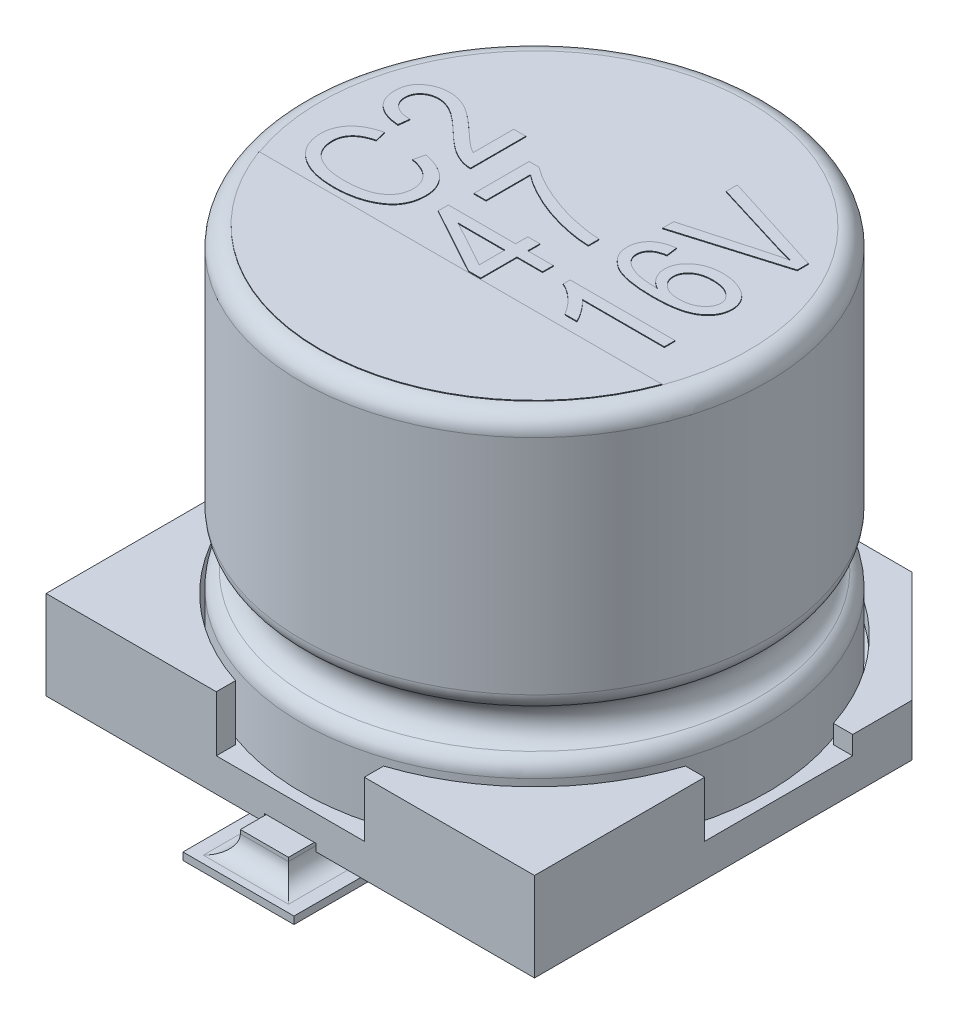
from build123d import *

# Parameters (mm, degrees)
SKETCH1_W                = 6.6
SKETCH1_H                = 6.6
BOSS_EXTRUDE1_DEPTH      = 1.2
CUT_EXTRUDE1_DEPTH       = 0.75
SKETCH3_W                = 3.3
SKETCH3_H                = 0.5
CUT_EXTRUDE2_DEPTH       = 4.3
CUT_EXTRUDE2_DEPTH_BACK  = 4.3
CHAMFER1_SIZE            = 1.5
CUT_EXTRUDE3_DEPTH       = 0.1
BOSS_EXTRUDE4_DEPTH      = 0.3
BOSS_EXTRUDE4_DEPTH_BACK = 0.1
SKETCH8_R                = 0.5
BOSS_EXTRUDE5_DEPTH      = 0.3
SKETCH9_W                = 1.5
SKETCH9_H                = 2
BOSS_EXTRUDE6_DEPTH      = 0.1
FILLET1_R                = 0.25
BOSS_EXTRUDE7_DEPTH      = 0.01


with BuildPart() as part:
    # Sketch1 → Boss-Extrude1 (new body)
    with BuildSketch(Plane(origin=(0, 0.3, 0), x_dir=(1, 0, 0), z_dir=(0, 1, 0))):
        Rectangle(SKETCH1_W, SKETCH1_H)
    extrude(amount=BOSS_EXTRUDE1_DEPTH)

    # Sketch2 → Cut-Extrude1 (cut)
    with BuildSketch(Plane(origin=(0, 1.5, 0), x_dir=(1, 0, 0), z_dir=(0, 1, 0))):
        with BuildLine():
            Line((-3.3, 1), (-3.039736831, 1))
            ThreePointArc((-3.039736831, 1), (-2.2627417, 2.2627417), (-1, 3.039736831))
            Line((-1, 3.039736831), (-1, 3.3))
            Line((-1, 3.3), (1, 3.3))
            Line((1, 3.3), (1, 3.039736831))
            ThreePointArc((1, 3.039736831), (2.2627417, 2.2627417), (3.039736831, 1))
            Line((3.039736831, 1), (3.3, 1))
            Line((3.3, 1), (3.3, -1))
            Line((3.3, -1), (3.039736831, -1))
            ThreePointArc((3.039736831, -1), (2.2627417, -2.2627417), (1, -3.039736831))
            Line((1, -3.039736831), (1, -3.3))
            Line((1, -3.3), (-1, -3.3))
            Line((-1, -3.3), (-1, -3.039736831))
            ThreePointArc((-1, -3.039736831), (-2.2627417, -2.2627417), (-3.039736831, -1))
            Line((-3.039736831, -1), (-3.3, -1))
            Line((-3.3, -1), (-3.3, 1))
        make_face()
    extrude(amount=-CUT_EXTRUDE1_DEPTH, mode=Mode.SUBTRACT)

    # Sketch3 → Cut-Extrude2 (cut, two sides)
    with BuildSketch(Plane(origin=(0, 0, 0), x_dir=(0, 0, -1), z_dir=(1, 0, 0))) as cut_extrude2_sk:
        with Locations((1.65, 1.25)):
            Rectangle(SKETCH3_W, SKETCH3_H)
    extrude(amount=CUT_EXTRUDE2_DEPTH, mode=Mode.SUBTRACT)
    extrude(cut_extrude2_sk.sketch, amount=-CUT_EXTRUDE2_DEPTH_BACK, mode=Mode.SUBTRACT)

    # Chamfer1
    chamfer1_edges = [part.edges().sort_by_distance(p)[0] for p in [
        (3.3, 0.65, -3.3),
        (-3.3, 0.65, -3.3),
    ]]
    chamfer(chamfer1_edges, length=CHAMFER1_SIZE)

    # Sketch7 → Cut-Extrude3 (cut)
    with BuildSketch(Plane.XZ.offset(-0.3)):
        with BuildLine():
            Line((-0.35, 3.3), (0.35, 3.3))
            Line((0.35, 3.3), (0.498675617, 1.261367968))
            ThreePointArc((0.498675617, 1.261367968), (0, 0.725), (-0.498675617, 1.261367968))
            Line((-0.498675617, 1.261367968), (-0.35, 3.3))
        make_face()
        with BuildLine():
            Line((-0.35, -3.3), (0.35, -3.3))
            Line((0.35, -3.3), (0.498675617, -1.261367968))
            ThreePointArc((0.498675617, -1.261367968), (0, -0.725), (-0.498675617, -1.261367968))
            Line((-0.498675617, -1.261367968), (-0.35, -3.3))
        make_face()
    extrude(amount=-CUT_EXTRUDE3_DEPTH, mode=Mode.SUBTRACT)

    # Sketch6 → Boss-Extrude4 (add, two sides)
    with BuildSketch(Plane.XZ.offset(-0.3)) as boss_extrude4_sk:
        with BuildLine():
            Line((-0.325, -1.225), (-0.325, -3.65))
            Line((-0.325, -3.65), (0.325, -3.65))
            Line((0.325, -3.65), (0.325, -1.225))
            ThreePointArc((0.325, -1.225), (0, -0.9), (-0.325, -1.225))
        make_face()
        with BuildLine():
            Line((-0.325, 1.225), (-0.325, 3.65))
            Line((-0.325, 3.65), (0.325, 3.65))
            Line((0.325, 3.65), (0.325, 1.225))
            ThreePointArc((0.325, 1.225), (0, 0.9), (-0.325, 1.225))
        make_face()
    extrude(amount=BOSS_EXTRUDE4_DEPTH)
    extrude(boss_extrude4_sk.sketch, amount=-BOSS_EXTRUDE4_DEPTH_BACK)

    # Sketch8 → Boss-Extrude5 (add)
    with BuildSketch(Plane.XZ.offset(-0.3)):
        with Locations((-2, 2)):
            Circle(SKETCH8_R)
        with Locations((2, 2)):
            Circle(SKETCH8_R)
        with Locations((2, -2)):
            Circle(SKETCH8_R)
        with Locations((-2, -2)):
            Circle(SKETCH8_R)
    extrude(amount=BOSS_EXTRUDE5_DEPTH)

    # Sketch9 → Boss-Extrude6 (add)
    with BuildSketch(Plane(origin=(0, 0, 0), x_dir=(1, 0, 0), z_dir=(0, 1, 0))):
        with Locations((0, 3)):
            Rectangle(SKETCH9_W, SKETCH9_H)
        with Locations((0, -3)):
            Rectangle(SKETCH9_W, SKETCH9_H)
    extrude(amount=BOSS_EXTRUDE6_DEPTH)

    # Fillet1
    fillet1_edges = [part.edges().sort_by_distance(p)[0] for p in [
        (0.325, 0.1, -2.825),
        (0, 0.1, -3.65),
        (-0.325, 0.1, -2.825),
        (-0.325, 0.1, 2.825),
        (0, 0.1, 3.65),
        (0.325, 0.1, 2.825),
    ]]
    fillet(fillet1_edges, radius=FILLET1_R)


with BuildPart() as body_2:
    # Sketch4 → Revolve1 (revolve)
    with BuildSketch(Plane(origin=(0, 0, 0), x_dir=(0, 0, -1), z_dir=(1, 0, 0))):
        with BuildLine():
            Line((0, 0.75), (0, 5.8))
            Line((0, 5.8), (-2.9, 5.8))
            ThreePointArc((-2.9, 5.8), (-3.076776695, 5.726776695), (-3.15, 5.55))
            Line((-3.15, 5.55), (-3.15, 2.539897949))
            ThreePointArc((-3.15, 2.539897949), (-3.113200716, 2.409339707), (-3.013636364, 2.317217063))
            ThreePointArc((-3.013636364, 2.317217063), (-2.85, 2.05), (-3.013636364, 1.782782937))
            ThreePointArc((-3.013636364, 1.782782937), (-3.113200716, 1.690660293), (-3.15, 1.560102051))
            Line((-3.15, 1.560102051), (-3.15, 0.75))
            Line((-3.15, 0.75), (0, 0.75))
        make_face()
    revolve(axis=Axis((0, 0, 0), (0, 1, 0)))

    # Sketch10 → Boss-Extrude7 (add)
    with BuildSketch(Plane(origin=(0, 5.8, 0), x_dir=(1, 0, 0), z_dir=(0, 1, 0))):
        with BuildLine():
            Line((-2.722131518, -1), (2.722131518, -1))
            ThreePointArc((2.722131518, -1), (0, -2.9), (-2.722131518, -1))
        make_face()
        with BuildLine():
            Line((-1.590909091, -0.054545455), (-1.554545455, 0.090909091))
            add(Edge.make_bspline(
                [(-1.554545455, 0.090909091), (-1.535269984, 0.086573907), (-1.497690858, 0.078122106), (-1.443641016, 0.062267336), (-1.39347407, 0.043748021), (-1.347020443, 0.023039775), (-1.304271779, 0.000124477), (-1.26542753, -0.02529249), (-1.230157415, -0.052859494), (-1.199022696, -0.0830881), (-1.1711564, -0.11498153), (-1.147359527, -0.148885394), (-1.126876496, -0.184353775), (-1.110494381, -0.221648338), (-1.097542958, -0.26053486), (-1.088602603, -0.301197149), (-1.082613039, -0.343476895), (-1.082085319, -0.372327427), (-1.081818182, -0.386931818)],
                knots=[0, 0, 0, 0, 5.9261e-05, 0.000115534, 0.000168835, 0.000219573, 0.000268003, 0.000314177, 0.000358679, 0.000402077, 0.00044417, 0.00048555, 0.000526144, 0.000566844, 0.00060754, 0.000648893, 0.000691602, 0.000735385, 0.000735385, 0.000735385, 0.000735385], degree=3))
            add(Edge.make_bspline(
                [(-1.081818182, -0.386931818), (-1.08199604, -0.399821435), (-1.082344685, -0.425088107), (-1.08628588, -0.462271509), (-1.092042775, -0.49811477), (-1.100709737, -0.532535089), (-1.111320422, -0.565607629), (-1.12494552, -0.597015472), (-1.140459369, -0.627260099), (-1.158765073, -0.656028269), (-1.179571172, -0.683485815), (-1.203389889, -0.709483177), (-1.230089597, -0.734193803), (-1.259944493, -0.757429014), (-1.292153583, -0.780002615), (-1.327732387, -0.800693244), (-1.366087752, -0.820236254), (-1.407117451, -0.838589504), (-1.450494312, -0.855557658), (-1.496291355, -0.869438478), (-1.543730677, -0.881811406), (-1.593174601, -0.891633014), (-1.644419194, -0.899736152), (-1.697742163, -0.904867658), (-1.752885478, -0.90849447), (-1.79033462, -0.908889873), (-1.809375, -0.909090909)],
                knots=[0, 0, 0, 0, 3.8653e-05, 7.5769e-05, 0.000112058, 0.000147474, 0.000182152, 0.000216135, 0.000250061, 0.00028403, 0.000318292, 0.000353282, 0.000389669, 0.000427294, 0.000466696, 0.000507575, 0.000550646, 0.000595789, 0.000642375, 0.000690268, 0.000739259, 0.000789402, 0.000841435, 0.000894833, 0.000950052, 0.001007166, 0.001007166, 0.001007166, 0.001007166], degree=3))
            add(Edge.make_bspline(
                [(-1.809375, -0.909090909), (-1.828131477, -0.908891515), (-1.864918777, -0.908500442), (-1.918927074, -0.904879558), (-1.970836199, -0.89976115), (-2.020467971, -0.891629314), (-2.068038414, -0.881875407), (-2.113230745, -0.869546812), (-2.156417451, -0.855465065), (-2.197183074, -0.838717593), (-2.23556886, -0.819854437), (-2.271703348, -0.799665669), (-2.305636674, -0.7782885), (-2.336754909, -0.754647483), (-2.365716723, -0.729906308), (-2.392050099, -0.703226401), (-2.415889386, -0.675051379), (-2.437612676, -0.645533861), (-2.456445194, -0.614609234), (-2.473168151, -0.582906747), (-2.487044041, -0.550190169), (-2.498446352, -0.516578306), (-2.507309721, -0.482103804), (-2.51340371, -0.446753631), (-2.517701953, -0.410616822), (-2.518020918, -0.386187094), (-2.518181818, -0.373863636)],
                knots=[0, 0, 0, 0, 5.6261e-05, 0.000110346, 0.000162332, 0.00021268, 0.000261154, 0.000307947, 0.000353135, 0.000397345, 0.000440035, 0.00048137, 0.000521484, 0.000560234, 0.000598505, 0.000635669, 0.000672553, 0.000709147, 0.000745495, 0.000781075, 0.000816587, 0.000851984, 0.000887469, 0.000923246, 0.000959544, 0.000996494, 0.000996494, 0.000996494, 0.000996494], degree=3))
            add(Edge.make_bspline(
                [(-2.518181818, -0.373863636), (-2.517836245, -0.360403658), (-2.517157421, -0.333963692), (-2.51232314, -0.2949276), (-2.50375071, -0.257491322), (-2.491963894, -0.221400738), (-2.477319506, -0.186648435), (-2.458926486, -0.153497861), (-2.437231843, -0.121829676), (-2.412151492, -0.091753334), (-2.384064112, -0.063268457), (-2.352642727, -0.037053667), (-2.318021615, -0.013198288), (-2.280592352, 0.008720064), (-2.239836161, 0.028077805), (-2.196104803, 0.045195718), (-2.149383072, 0.060899358), (-2.116737437, 0.06871843), (-2.1, 0.072727273)],
                knots=[0, 0, 0, 0, 4.0377e-05, 7.9314e-05, 0.00011777, 0.000155413, 0.000193089, 0.000230727, 0.000268944, 0.000308083, 0.000348059, 0.000388798, 0.000430644, 0.000474058, 0.000518786, 0.000565843, 0.000614895, 0.000666503, 0.000666503, 0.000666503, 0.000666503], degree=3))
            Line((-2.1, 0.072727273), (-2.063636364, -0.072727273))
            add(Edge.make_bspline(
                [(-2.063636364, -0.072727273), (-2.075415657, -0.076014842), (-2.09838882, -0.082426589), (-2.131385283, -0.093836475), (-2.16212884, -0.106315751), (-2.190702493, -0.119878322), (-2.216858294, -0.134981345), (-2.240809391, -0.151183398), (-2.262622459, -0.168512213), (-2.281837552, -0.18733177), (-2.299174934, -0.207015726), (-2.314027101, -0.228167261), (-2.326434713, -0.250610755), (-2.336864821, -0.274143399), (-2.344710122, -0.29883956), (-2.350488764, -0.324780444), (-2.353897302, -0.351897099), (-2.354327694, -0.370445051), (-2.354545455, -0.379829545)],
                knots=[0, 0, 0, 0, 3.6682e-05, 7.1541e-05, 0.000104671, 0.000136183, 0.000166347, 0.000195186, 0.000222871, 0.000249792, 0.000275769, 0.000301463, 0.000327153, 0.000352594, 0.000378559, 0.000404751, 0.000432236, 0.000460383, 0.000460383, 0.000460383, 0.000460383], degree=3))
            add(Edge.make_bspline(
                [(-2.354545455, -0.379829545), (-2.35385919, -0.398352683), (-2.352520049, -0.434497777), (-2.341380909, -0.486774554), (-2.32356338, -0.535415072), (-2.302183567, -0.572435813), (-2.281676826, -0.599884003), (-2.264145966, -0.619341158), (-2.244571744, -0.637656309), (-2.223156065, -0.655079621), (-2.199729148, -0.671452407), (-2.174116674, -0.68659933), (-2.146678058, -0.700674648), (-2.117280199, -0.71391907), (-2.085725363, -0.725452856), (-2.052144458, -0.735658997), (-2.016608107, -0.744497484), (-1.97904312, -0.751570884), (-1.939483915, -0.756840566), (-1.897893335, -0.760900414), (-1.854284805, -0.763081061), (-1.824528656, -0.763448991), (-1.809375, -0.763636364)],
                knots=[0, 0, 0, 0, 5.5521e-05, 0.00010834, 0.000159579, 0.000210356, 0.000235924, 0.000262277, 0.000288806, 0.00031627, 0.000345037, 0.000374464, 0.000405467, 0.000437514, 0.00047113, 0.000506178, 0.000542765, 0.000580932, 0.000620788, 0.000662455, 0.000706264, 0.000751727, 0.000751727, 0.000751727, 0.000751727], degree=3))
            add(Edge.make_bspline(
                [(-1.809375, -0.763636364), (-1.7866406, -0.763277052), (-1.742545554, -0.76258014), (-1.678505163, -0.758136361), (-1.618781, -0.750361716), (-1.56357216, -0.73894853), (-1.512700987, -0.724850823), (-1.466148021, -0.70769878), (-1.424108709, -0.686842239), (-1.3864956, -0.663014636), (-1.353335841, -0.636428646), (-1.324444791, -0.607743969), (-1.300117612, -0.576779572), (-1.279890257, -0.543911532), (-1.264590564, -0.508650459), (-1.253399106, -0.471491449), (-1.246760222, -0.43214949), (-1.24589616, -0.405233711), (-1.245454545, -0.391477273)],
                knots=[0, 0, 0, 0, 6.8203e-05, 0.000132285, 0.000192472, 0.000248745, 0.00030127, 0.000350714, 0.000397341, 0.00044179, 0.000484028, 0.000524606, 0.000563651, 0.000601898, 0.00064006, 0.000678618, 0.000718083, 0.000759339, 0.000759339, 0.000759339, 0.000759339], degree=3))
            add(Edge.make_bspline(
                [(-1.245454545, -0.391477273), (-1.245736078, -0.381236028), (-1.246290868, -0.361054538), (-1.250438864, -0.331302808), (-1.25684292, -0.302519826), (-1.266278016, -0.274802746), (-1.278603487, -0.248317216), (-1.293435518, -0.222915999), (-1.310955246, -0.1985858), (-1.331001303, -0.175372212), (-1.35388971, -0.153621502), (-1.379633959, -0.133728141), (-1.407978223, -0.115505231), (-1.439304302, -0.099629671), (-1.473213821, -0.085434106), (-1.509927287, -0.072944059), (-1.549417404, -0.062419489), (-1.576856124, -0.057212339), (-1.590909091, -0.054545455)],
                knots=[0, 0, 0, 0, 3.0715e-05, 6.0527e-05, 8.9954e-05, 0.000119062, 0.00014817, 0.000177454, 0.000207176, 0.00023799, 0.000269338, 0.00030173, 0.000335459, 0.000370273, 0.000406942, 0.000445663, 0.000486527, 0.000529427, 0.000529427, 0.000529427, 0.000529427], degree=3))
        make_face()
        with BuildLine():
            Line((-1.263636364, 0.981818182), (-1.1, 0.981818182))
            Line((-1.1, 0.981818182), (-1.1, 0.236363636))
            add(Edge.make_bspline(
                [(-1.1, 0.236363636), (-1.108526139, 0.236329121), (-1.125800237, 0.236259193), (-1.152136122, 0.238584079), (-1.179109616, 0.243360755), (-1.207080544, 0.249460089), (-1.235681047, 0.258108257), (-1.265050018, 0.268695301), (-1.295114638, 0.281186756), (-1.326051768, 0.295814413), (-1.358163014, 0.312902254), (-1.391293946, 0.333544589), (-1.426060056, 0.357133193), (-1.462027805, 0.384239565), (-1.499539059, 0.414376038), (-1.538420082, 0.447691337), (-1.578884511, 0.484046326), (-1.605760934, 0.509953354), (-1.619602273, 0.523295455)],
                knots=[0, 0, 0, 0, 2.557e-05, 5.1805e-05, 7.9173e-05, 0.000107707, 0.000137639, 0.000168732, 0.000201336, 0.000235267, 0.000271364, 0.000310392, 0.000352311, 0.000397368, 0.000445463, 0.000496645, 0.000550956, 0.000608626, 0.000608626, 0.000608626, 0.000608626], degree=3))
            add(Edge.make_bspline(
                [(-1.619602273, 0.523295455), (-1.635637271, 0.538798259), (-1.666511412, 0.568647703), (-1.712098974, 0.610657945), (-1.754472047, 0.648828469), (-1.79439686, 0.682396652), (-1.831329649, 0.711958454), (-1.865217609, 0.737811297), (-1.896829804, 0.758719674), (-1.934026094, 0.781294777), (-1.978307687, 0.802816931), (-2.029924889, 0.821843734), (-2.079823364, 0.834137484), (-2.112720366, 0.835636031), (-2.128693182, 0.836363636)],
                knots=[0, 0, 0, 0, 6.6909e-05, 0.000128827, 0.000185969, 0.000237984, 0.00028528, 0.000327894, 0.000365793, 0.000398924, 0.000458385, 0.000513117, 0.000563838, 0.000611708, 0.000611708, 0.000611708, 0.000611708], degree=3))
            add(Edge.make_bspline(
                [(-2.128693182, 0.836363636), (-2.137511466, 0.836262209), (-2.154734496, 0.836064109), (-2.179886592, 0.832696429), (-2.20381126, 0.827895556), (-2.226676172, 0.821550373), (-2.248124534, 0.812577909), (-2.268306101, 0.801705089), (-2.28748668, 0.78927231), (-2.305000247, 0.774764414), (-2.320799928, 0.758906262), (-2.334944309, 0.74215364), (-2.34650537, 0.724224166), (-2.356081715, 0.705487317), (-2.363408979, 0.685830846), (-2.368899131, 0.665304412), (-2.372018106, 0.643845165), (-2.37248854, 0.629270992), (-2.372727273, 0.621875)],
                knots=[0, 0, 0, 0, 2.6434e-05, 5.1629e-05, 7.5976e-05, 9.9624e-05, 0.000122679, 0.000145557, 0.000168329, 0.000191136, 0.000213634, 0.000235423, 0.000256777, 0.000277486, 0.000298434, 0.000319589, 0.000341123, 0.000363312, 0.000363312, 0.000363312, 0.000363312], degree=3))
            add(Edge.make_bspline(
                [(-2.372727273, 0.621875), (-2.37256065, 0.613900574), (-2.372235395, 0.59833413), (-2.36816798, 0.575651584), (-2.362773189, 0.553892243), (-2.354244328, 0.533328095), (-2.34393617, 0.513567435), (-2.330480705, 0.495423159), (-2.315464229, 0.477851762), (-2.297847597, 0.461699801), (-2.277843958, 0.447282103), (-2.255995759, 0.434340392), (-2.231759102, 0.423909264), (-2.205732976, 0.415143025), (-2.177605795, 0.408257148), (-2.147464409, 0.403659769), (-2.115321715, 0.400286651), (-2.093191418, 0.400097308), (-2.081818182, 0.4)],
                knots=[0, 0, 0, 0, 2.3891e-05, 4.6636e-05, 6.8962e-05, 9.1013e-05, 0.000113256, 0.000135647, 0.000158604, 0.00018253, 0.000207134, 0.000232471, 0.000258547, 0.000286127, 0.000314791, 0.00034529, 0.000377544, 0.000411645, 0.000411645, 0.000411645, 0.000411645], degree=3))
            Line((-2.081818182, 0.4), (-2.1, 0.254545455))
            add(Edge.make_bspline(
                [(-2.1, 0.254545455), (-2.116878864, 0.256044403), (-2.149624625, 0.258952431), (-2.197028868, 0.266582878), (-2.241012726, 0.277169397), (-2.282009501, 0.289743194), (-2.319529308, 0.305538117), (-2.354259092, 0.323315632), (-2.385594771, 0.344104712), (-2.41358887, 0.367471303), (-2.438135931, 0.393219601), (-2.459470498, 0.420881428), (-2.477973713, 0.450326621), (-2.492661358, 0.48196961), (-2.504113656, 0.515601078), (-2.512301557, 0.551095677), (-2.517184689, 0.588595521), (-2.517844532, 0.61418989), (-2.518181818, 0.627272727)],
                knots=[0, 0, 0, 0, 5.0826e-05, 9.8605e-05, 0.000143876, 0.000186465, 0.00022709, 0.000265845, 0.000303351, 0.000339652, 0.000375017, 0.00040985, 0.0004443, 0.000479123, 0.00051425, 0.000550705, 0.000588233, 0.000627474, 0.000627474, 0.000627474, 0.000627474], degree=3))
            add(Edge.make_bspline(
                [(-2.518181818, 0.627272727), (-2.51777024, 0.641399278), (-2.51696883, 0.66890602), (-2.511606791, 0.708928303), (-2.502364468, 0.746367717), (-2.488775473, 0.780952896), (-2.472086687, 0.813059839), (-2.451359855, 0.842398159), (-2.426718946, 0.8689373), (-2.398630231, 0.892533787), (-2.368318477, 0.913392859), (-2.336619301, 0.931592245), (-2.304062219, 0.947379151), (-2.270283829, 0.959716965), (-2.235737761, 0.970020381), (-2.199900262, 0.976493207), (-2.163184854, 0.98105003), (-2.138366747, 0.981560685), (-2.125852273, 0.981818182)],
                knots=[0, 0, 0, 0, 4.2376e-05, 8.2514e-05, 0.000120892, 0.000157769, 0.000193732, 0.000229202, 0.000265187, 0.000302072, 0.000339031, 0.000375431, 0.000411646, 0.000447423, 0.000483207, 0.000519646, 0.000556541, 0.000594068, 0.000594068, 0.000594068, 0.000594068], degree=3))
            add(Edge.make_bspline(
                [(-2.125852273, 0.981818182), (-2.11457728, 0.981575571), (-2.092174188, 0.98109351), (-2.058747505, 0.977957666), (-2.025770218, 0.972422318), (-1.992925237, 0.965234918), (-1.960721139, 0.955035926), (-1.928646367, 0.943490202), (-1.897063055, 0.92948583), (-1.865353596, 0.912954493), (-1.832400362, 0.893593658), (-1.797582813, 0.870413663), (-1.75999161, 0.843695117), (-1.720068327, 0.812894269), (-1.677371403, 0.778503223), (-1.632239704, 0.74007834), (-1.584581066, 0.697748991), (-1.552225242, 0.667949952), (-1.535511364, 0.652556818)],
                knots=[0, 0, 0, 0, 3.3826e-05, 6.7211e-05, 0.000100605, 0.0001341, 0.000167978, 0.000201861, 0.000236331, 0.000271528, 0.000309093, 0.000350933, 0.00039697, 0.000447427, 0.000502177, 0.000561433, 0.000625227, 0.000693392, 0.000693392, 0.000693392, 0.000693392], degree=3))
            add(Edge.make_bspline(
                [(-1.535511364, 0.652556818), (-1.525120683, 0.642774978), (-1.505263257, 0.624081097), (-1.476459517, 0.597787932), (-1.450627532, 0.573694445), (-1.427113376, 0.552619595), (-1.406420699, 0.533879053), (-1.387872289, 0.518474586), (-1.372371784, 0.50522937), (-1.347533386, 0.485906517), (-1.312497714, 0.461520393), (-1.279547873, 0.444555837), (-1.263636364, 0.436363636)],
                knots=[0, 0, 0, 0, 4.2811e-05, 8.1815e-05, 0.000116998, 0.000148778, 0.000176546, 0.000200736, 0.000221105, 0.0002377, 0.000295143, 0.000348787, 0.000348787, 0.000348787, 0.000348787], degree=3))
            Line((-1.263636364, 0.436363636), (-1.263636364, 0.981818182))
        make_face()
        Polygon((0.6, -0.490909091), (0.254545455, -0.490909091), (0.254545455, -0.981818182), (0.090909091, -0.981818182), (-0.818181818, -0.482670455), (-0.818181818, -0.345454545), (0.090909091, -0.345454545), (0.090909091, -0.181818182), (0.254545455, -0.181818182), (0.254545455, -0.345454545), (0.6, -0.345454545), align=None)
        Polygon((0.090909091, -0.490909091), (-0.541761364, -0.490909091), (0.090909091, -0.838352273), align=None, mode=Mode.SUBTRACT)
        with BuildLine():
            Line((-0.618181818, -0.036363636), (-0.781818182, -0.036363636))
            Line((-0.781818182, -0.036363636), (-0.781818182, 0.709090909))
            Line((-0.781818182, 0.709090909), (-0.648011364, 0.709090909))
            add(Edge.make_bspline(
                [(-0.648011364, 0.709090909), (-0.629493997, 0.695259816), (-0.591802758, 0.667107268), (-0.531511589, 0.627736674), (-0.467300458, 0.589447284), (-0.399115474, 0.552202178), (-0.326735965, 0.516442976), (-0.250395077, 0.481792677), (-0.169863353, 0.448671938), (-0.086180255, 0.416771358), (-0.000509186, 0.387072726), (0.085833546, 0.360699392), (0.172037252, 0.337560436), (0.258041112, 0.318119267), (0.343740707, 0.301430866), (0.429233175, 0.288433289), (0.514618592, 0.278624638), (0.571572289, 0.274690798), (0.6, 0.272727273)],
                knots=[0, 0, 0, 0, 6.9323e-05, 0.000141105, 0.000215892, 0.000293569, 0.000374119, 0.000458032, 0.000545029, 0.000635305, 0.000726675, 0.000816989, 0.000906092, 0.000994375, 0.001081459, 0.001167964, 0.001253736, 0.001339214, 0.001339214, 0.001339214, 0.001339214], degree=3))
            Line((0.6, 0.272727273), (0.6, 0.127272727))
            add(Edge.make_bspline(
                [(0.6, 0.127272727), (0.585031616, 0.127721783), (0.554496113, 0.128637858), (0.507812363, 0.132321595), (0.459263961, 0.136926159), (0.408898623, 0.14395977), (0.356690679, 0.152404131), (0.302660797, 0.16282712), (0.246691588, 0.174269157), (0.169998372, 0.192613669), (0.07400088, 0.218383212), (-0.039052852, 0.255716866), (-0.149665888, 0.297377526), (-0.256248385, 0.345139752), (-0.357722591, 0.395822213), (-0.451901767, 0.449612447), (-0.539097534, 0.503996466), (-0.592310728, 0.544126176), (-0.618181818, 0.563636364)],
                knots=[0, 0, 0, 0, 4.4919e-05, 9.1634e-05, 0.000140453, 0.000191197, 0.00024416, 0.000299098, 0.000356263, 0.000415524, 0.000535646, 0.000654323, 0.000772562, 0.000890077, 0.001004549, 0.001112692, 0.001215383, 0.001312548, 0.001312548, 0.001312548, 0.001312548], degree=3))
            Line((-0.618181818, 0.563636364), (-0.618181818, -0.036363636))
        make_face()
        with BuildLine():
            Line((2.3, -0.4), (2.3, -0.545454545))
            Line((2.3, -0.545454545), (1.190909091, -0.545454545))
            add(Edge.make_bspline(
                [(1.190909091, -0.545454545), (1.201187583, -0.554390899), (1.222489747, -0.572911482), (1.252821972, -0.60494637), (1.283744861, -0.640961759), (1.314142583, -0.680475653), (1.343094492, -0.721004913), (1.369022417, -0.760723301), (1.391194556, -0.798732178), (1.403286622, -0.824158704), (1.409090909, -0.836363636)],
                knots=[0, 0, 0, 0, 4.0839e-05, 8.4639e-05, 0.000132185, 0.000183214, 0.000234138, 0.000281575, 0.00032548, 0.00036601, 0.00036601, 0.00036601, 0.00036601], degree=3))
            Line((1.409090909, -0.836363636), (1.245454545, -0.836363636))
            add(Edge.make_bspline(
                [(1.245454545, -0.836363636), (1.233642199, -0.816748251), (1.210118652, -0.777685441), (1.169417041, -0.722834292), (1.125143852, -0.671296873), (1.077511838, -0.624163795), (1.028626141, -0.581775948), (0.979606546, -0.545645228), (0.931206448, -0.51592592), (0.897903798, -0.50135576), (0.881818182, -0.494318182)],
                knots=[0, 0, 0, 0, 6.8659e-05, 0.00013673, 0.000204613, 0.000272311, 0.000337575, 0.000398545, 0.000454866, 0.000507487, 0.000507487, 0.000507487, 0.000507487], degree=3))
            Line((0.881818182, -0.494318182), (0.881818182, -0.4))
            Line((0.881818182, -0.4), (2.3, -0.4))
        make_face()
        with BuildLine():
            Line((1.227272727, 0.690909091), (1.245454545, 0.545454545))
            add(Edge.make_bspline(
                [(1.245454545, 0.545454545), (1.228888789, 0.542092373), (1.197868713, 0.535796564), (1.155846338, 0.522141027), (1.120711583, 0.506926235), (1.102068626, 0.492856198), (1.093465909, 0.486363636)],
                knots=[0, 0, 0, 0, 5.0658e-05, 9.486e-05, 0.00013248, 0.000164714, 0.000164714, 0.000164714, 0.000164714], degree=3))
            add(Edge.make_bspline(
                [(1.093465909, 0.486363636), (1.088151366, 0.481642121), (1.077817659, 0.47246151), (1.06443174, 0.457203296), (1.052895267, 0.441493714), (1.043396289, 0.424973026), (1.036294313, 0.407446484), (1.031211008, 0.389240358), (1.027970319, 0.370378725), (1.02750664, 0.357588599), (1.027272727, 0.351136364)],
                knots=[0, 0, 0, 0, 2.1309e-05, 4.1433e-05, 6.0753e-05, 7.9711e-05, 9.8439e-05, 0.000117327, 0.000136335, 0.000155687, 0.000155687, 0.000155687, 0.000155687], degree=3))
            add(Edge.make_bspline(
                [(1.027272727, 0.351136364), (1.027643592, 0.341140794), (1.028378351, 0.32133756), (1.036299776, 0.29259891), (1.048194188, 0.265239754), (1.065396873, 0.239642765), (1.087299439, 0.215759119), (1.113695286, 0.193080537), (1.145190329, 0.172459963), (1.1683489, 0.160489366), (1.180397727, 0.154261364)],
                knots=[0, 0, 0, 0, 2.9916e-05, 5.927e-05, 8.8778e-05, 0.000119113, 0.000151295, 0.000185745, 0.00022325, 0.000263926, 0.000263926, 0.000263926, 0.000263926], degree=3))
            add(Edge.make_bspline(
                [(1.180397727, 0.154261364), (1.191962823, 0.149034298), (1.216006909, 0.138167115), (1.255189325, 0.125423701), (1.298133663, 0.114225257), (1.345214897, 0.105828484), (1.395945211, 0.098194453), (1.450776138, 0.093327091), (1.50943165, 0.090145929), (1.549900669, 0.089712047), (1.570738636, 0.089488636)],
                knots=[0, 0, 0, 0, 3.8049e-05, 7.9105e-05, 0.00012341, 0.000171105, 0.000222491, 0.000277276, 0.000336166, 0.000398676, 0.000398676, 0.000398676, 0.000398676], degree=3))
            add(Edge.make_bspline(
                [(1.570738636, 0.089488636), (1.556560753, 0.097725733), (1.52897336, 0.113753515), (1.492799332, 0.143597703), (1.461338332, 0.17571945), (1.435700878, 0.211098792), (1.41578701, 0.248661976), (1.401491233, 0.287551141), (1.392514241, 0.327527921), (1.391445574, 0.354594227), (1.390909091, 0.368181818)],
                knots=[0, 0, 0, 0, 4.9116e-05, 9.557e-05, 0.000140173, 0.000183701, 0.000226147, 0.000267312, 0.00030771, 0.000348434, 0.000348434, 0.000348434, 0.000348434], degree=3))
            add(Edge.make_bspline(
                [(1.390909091, 0.368181818), (1.391301908, 0.37947435), (1.392076125, 0.401731205), (1.397935225, 0.434574693), (1.407678703, 0.46619161), (1.421078749, 0.496875415), (1.438700941, 0.526321122), (1.459989424, 0.55473775), (1.485384314, 0.581768718), (1.513778366, 0.607887329), (1.545762775, 0.631597453), (1.580606808, 0.652393143), (1.617945468, 0.67013848), (1.658109338, 0.68422275), (1.700620967, 0.695643016), (1.74586758, 0.703570359), (1.793660139, 0.708012019), (1.826411295, 0.708725543), (1.843181818, 0.709090909)],
                knots=[0, 0, 0, 0, 3.3865e-05, 6.6746e-05, 9.9726e-05, 0.000132927, 0.000166935, 0.000202447, 0.000239235, 0.000278048, 0.000318048, 0.000358438, 0.000399612, 0.000441845, 0.000485947, 0.000531533, 0.000579476, 0.000629789, 0.000629789, 0.000629789, 0.000629789], degree=3))
            add(Edge.make_bspline(
                [(1.843181818, 0.709090909), (1.865940629, 0.708510813), (1.910522693, 0.707374467), (1.975798442, 0.697853255), (2.037715145, 0.681816353), (2.086798735, 0.663659874), (2.123564453, 0.646174993), (2.149231877, 0.632320376), (2.172901252, 0.617317941), (2.195178857, 0.602033393), (2.214942951, 0.584975548), (2.233426741, 0.567774568), (2.249571641, 0.549145547), (2.268698238, 0.523655154), (2.28874725, 0.490162677), (2.30557452, 0.447135236), (2.316278443, 0.402226709), (2.317544283, 0.371460964), (2.318181818, 0.355965909)],
                knots=[0, 0, 0, 0, 6.8253e-05, 0.000133701, 0.000197368, 0.000259846, 0.000290344, 0.000319456, 0.000347281, 0.000374395, 0.000400403, 0.000425521, 0.000450081, 0.000474229, 0.000521099, 0.000566627, 0.000612387, 0.000658819, 0.000658819, 0.000658819, 0.000658819], degree=3))
            add(Edge.make_bspline(
                [(2.318181818, 0.355965909), (2.317691664, 0.342010757), (2.316727601, 0.314562996), (2.309050836, 0.274378579), (2.296867201, 0.236064049), (2.27958791, 0.199563657), (2.257265816, 0.164973364), (2.229710866, 0.132591642), (2.197512918, 0.10196948), (2.160507284, 0.073047837), (2.117363709, 0.047045263), (2.067941211, 0.024355548), (2.011839884, 0.005399942), (1.94919517, -0.009536), (1.880148929, -0.021787042), (1.804634104, -0.030399859), (1.722513582, -0.035469899), (1.665632603, -0.036058055), (1.636079545, -0.036363636)],
                knots=[0, 0, 0, 0, 4.184e-05, 8.2292e-05, 0.000122273, 0.000162176, 0.000203074, 0.000245414, 0.000289419, 0.000336187, 0.000386029, 0.000440178, 0.000499023, 0.000563378, 0.000633205, 0.000709285, 0.000791262, 0.000879915, 0.000879915, 0.000879915, 0.000879915], degree=3))
            add(Edge.make_bspline(
                [(1.636079545, -0.036363636), (1.603305255, -0.036094702), (1.540170663, -0.035576643), (1.449090047, -0.030014357), (1.365309726, -0.021600486), (1.288866255, -0.009061535), (1.219622777, 0.006472035), (1.157689709, 0.026126761), (1.102740274, 0.048688873), (1.055355342, 0.075814664), (1.014476479, 0.105480524), (0.97930089, 0.137249763), (0.949000925, 0.170571279), (0.924311914, 0.206245054), (0.905466497, 0.244219922), (0.891582235, 0.283958428), (0.883542405, 0.325909704), (0.882398812, 0.354511992), (0.881818182, 0.369034091)],
                knots=[0, 0, 0, 0, 9.831e-05, 0.000189379, 0.000273648, 0.000350803, 0.000421647, 0.000486336, 0.000545537, 0.000599485, 0.000649718, 0.000696786, 0.000741447, 0.000784551, 0.000826477, 0.000868254, 0.000910487, 0.000954046, 0.000954046, 0.000954046, 0.000954046], degree=3))
            add(Edge.make_bspline(
                [(0.881818182, 0.369034091), (0.88211765, 0.379555387), (0.88270796, 0.400294916), (0.886582427, 0.430807456), (0.893814712, 0.459878127), (0.903566333, 0.487625163), (0.915663578, 0.514288677), (0.931219954, 0.539251809), (0.949252006, 0.563066082), (0.969992985, 0.585418625), (0.993267363, 0.6063684), (1.019605328, 0.624677841), (1.04811713, 0.641196369), (1.079013501, 0.655861124), (1.11254524, 0.667933113), (1.148573562, 0.677796225), (1.186975614, 0.685905338), (1.21360504, 0.689211954), (1.227272727, 0.690909091)],
                knots=[0, 0, 0, 0, 3.1566e-05, 6.2223e-05, 9.2058e-05, 0.000121258, 0.000150366, 0.000179698, 0.000209301, 0.000239859, 0.000271048, 0.000303049, 0.000335891, 0.000369822, 0.000405501, 0.000442652, 0.00048182, 0.000523122, 0.000523122, 0.000523122, 0.000523122], degree=3))
        make_face()
        with BuildLine():
            add(Edge.make_bspline(
                [(1.837784091, 0.109090909), (1.850102241, 0.109299566), (1.874125052, 0.109706487), (1.90926333, 0.113153393), (1.942538217, 0.118929419), (1.974140993, 0.126260744), (2.003549298, 0.136806756), (2.031395969, 0.148861304), (2.057161391, 0.163737555), (2.08105205, 0.180441229), (2.102391824, 0.198691241), (2.121071193, 0.217945946), (2.137105456, 0.237680349), (2.149972193, 0.258474392), (2.160460141, 0.2797765), (2.167444219, 0.302118458), (2.171929301, 0.325009273), (2.172460461, 0.340509441), (2.172727273, 0.348295455)],
                knots=[0, 0, 0, 0, 3.6949e-05, 7.2058e-05, 0.000105779, 0.000138233, 0.00016923, 0.000199373, 0.000229148, 0.00025831, 0.000286721, 0.00031324, 0.000338707, 0.000362828, 0.000386463, 0.000409732, 0.000432855, 0.000456194, 0.000456194, 0.000456194, 0.000456194], degree=3))
            add(Edge.make_bspline(
                [(2.172727273, 0.348295455), (2.172428819, 0.355224503), (2.17183519, 0.369006472), (2.167840785, 0.389330113), (2.16075589, 0.408891414), (2.151411533, 0.428068793), (2.139004698, 0.446609612), (2.123928734, 0.464502475), (2.105983244, 0.481521888), (2.086082333, 0.498395968), (2.063343969, 0.513403563), (2.038940857, 0.527460465), (2.011901072, 0.538178344), (1.98325262, 0.547808023), (1.9522647, 0.554632144), (1.919498862, 0.560257618), (1.884510312, 0.562846113), (1.860608561, 0.563367677), (1.848295455, 0.563636364)],
                knots=[0, 0, 0, 0, 2.0787e-05, 4.1346e-05, 6.1832e-05, 8.305e-05, 0.000105191, 0.000128579, 0.00015309, 0.000179316, 0.000206736, 0.000234716, 0.000263628, 0.000293814, 0.000325307, 0.000358701, 0.000393476, 0.000430425, 0.000430425, 0.000430425, 0.000430425], degree=3))
            add(Edge.make_bspline(
                [(1.848295455, 0.563636364), (1.836264519, 0.563378694), (1.812926375, 0.562878854), (1.778827026, 0.560144934), (1.746928488, 0.555059652), (1.716950204, 0.548000868), (1.689270215, 0.538572416), (1.663343495, 0.527586851), (1.639717147, 0.514105651), (1.618159085, 0.498918332), (1.599216622, 0.481977261), (1.582134848, 0.464548352), (1.568406824, 0.445533005), (1.556309172, 0.426225205), (1.547712381, 0.405496771), (1.540886755, 0.384081266), (1.537339548, 0.361574158), (1.536690406, 0.346316734), (1.536363636, 0.338636364)],
                knots=[0, 0, 0, 0, 3.6097e-05, 7.0023e-05, 0.00010253, 0.000132918, 0.000162294, 0.00019016, 0.000217258, 0.000243744, 0.000269106, 0.00029342, 0.000316773, 0.000339331, 0.000361601, 0.000383887, 0.000406632, 0.000429687, 0.000429687, 0.000429687, 0.000429687], degree=3))
            add(Edge.make_bspline(
                [(1.536363636, 0.338636364), (1.536521087, 0.331038772), (1.536832376, 0.316017883), (1.541156161, 0.294055218), (1.54724935, 0.272677347), (1.556619773, 0.252254121), (1.567906744, 0.232229942), (1.581976203, 0.213112913), (1.598667163, 0.194885761), (1.617544914, 0.177333509), (1.638690326, 0.161235469), (1.661887902, 0.147150406), (1.686968214, 0.135676941), (1.713632566, 0.12588541), (1.742135426, 0.11819808), (1.772469164, 0.112915065), (1.804573655, 0.109766108), (1.826507858, 0.109320165), (1.837784091, 0.109090909)],
                knots=[0, 0, 0, 0, 2.2756e-05, 4.4989e-05, 6.6921e-05, 8.9305e-05, 0.000112209, 0.000135791, 0.000160328, 0.000186261, 0.000213023, 0.000239917, 0.000267498, 0.000295628, 0.000325055, 0.000355928, 0.000387899, 0.000421725, 0.000421725, 0.000421725, 0.000421725], degree=3))
        make_face(mode=Mode.SUBTRACT)
        with BuildLine():
            Line((2.3, 1.250852273), (0.9, 0.832102273))
            Line((0.9, 0.832102273), (0.9, 0.981818182))
            Line((0.9, 0.981818182), (1.915625, 1.261931818))
            add(Edge.make_bspline(
                [(1.915625, 1.261931818), (1.93502513, 1.267188611), (1.973113627, 1.277509333), (2.029419911, 1.291882434), (2.083540048, 1.305617864), (2.119023676, 1.314057553), (2.136363636, 1.318181818)],
                knots=[0, 0, 0, 0, 6.0298e-05, 0.000118384, 0.000174333, 0.000227803, 0.000227803, 0.000227803, 0.000227803], degree=3))
            add(Edge.make_bspline(
                [(2.136363636, 1.318181818), (2.100128509, 1.327526981), (2.026165891, 1.346602192), (1.952964299, 1.368417642), (1.915625, 1.379545455)],
                knots=[0, 0, 0, 0, 0.000112252, 0.000229127, 0.000229127, 0.000229127, 0.000229127], degree=3))
            Line((1.915625, 1.379545455), (0.9, 1.690909091))
            Line((0.9, 1.690909091), (0.9, 1.842045455))
            Line((0.9, 1.842045455), (2.3, 1.401136364))
            Line((2.3, 1.401136364), (2.3, 1.250852273))
        make_face()
    extrude(amount=BOSS_EXTRUDE7_DEPTH)


solid = Compound([part.part, body_2.part])
